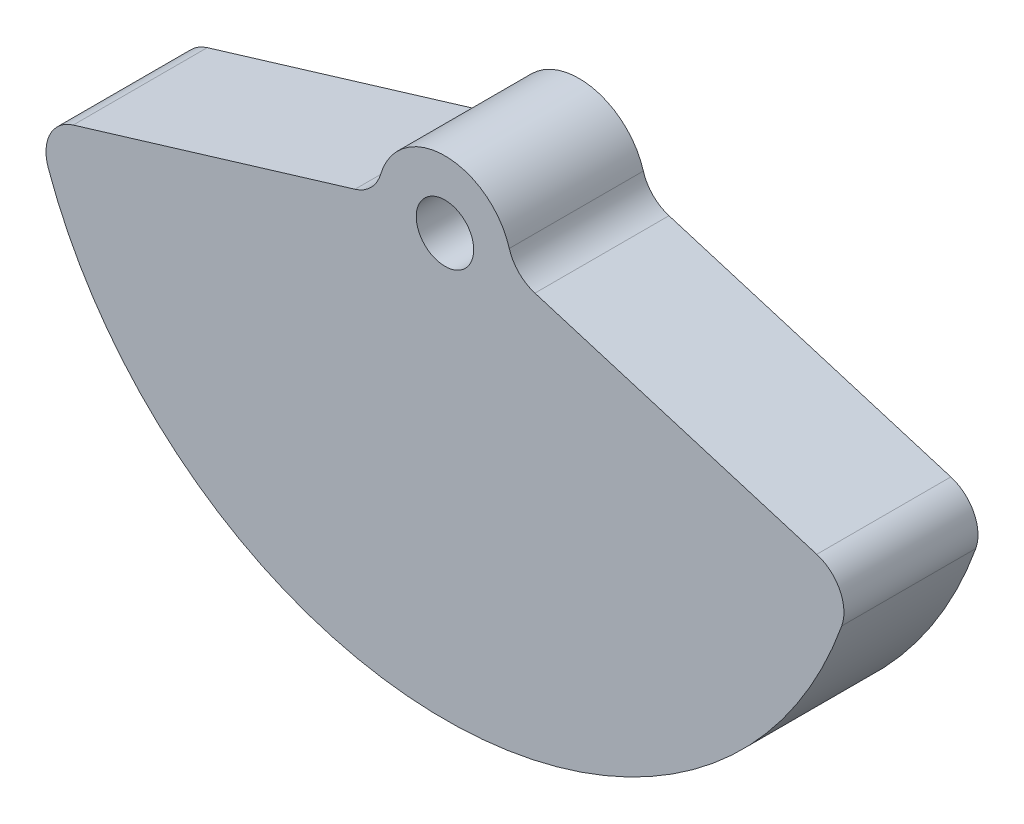
from build123d import *

# Parameters (mm, degrees)
SKETCH2_R           = 19.05
BOSS_EXTRUDE1_DEPTH = 44.45
SCALE1_SCALE        = 0.083333333


with BuildPart() as part:
    # Sketch2 → Boss-Extrude1 (new body, symmetric)
    with BuildSketch(Plane.XY):
        with BuildLine():
            Line((-246.541287735, -61.175642711), (-59.652807836, -4.602086269))
            ThreePointArc((-59.652807836, -4.602086269), (-48.980567788, 1.8190908), (-42.643954444, 12.541756231))
            ThreePointArc((-42.643954444, 12.541756231), (0, 44.45), (42.643954444, 12.541756231))
            ThreePointArc((42.643954444, 12.541756231), (48.980567788, 1.8190908), (59.652807836, -4.602086269))
            Line((59.652807836, -4.602086269), (246.541287735, -61.175642711))
            ThreePointArc((246.541287735, -61.175642711), (261.864746274, -74.055516083), (263.100383875, -94.034823363))
            ThreePointArc((263.100383875, -94.034823363), (0, -279.4), (-263.100383875, -94.034823363))
            ThreePointArc((-263.100383875, -94.034823363), (-261.864746274, -74.055516083), (-246.541287735, -61.175642711))
        make_face()
        Circle(SKETCH2_R, mode=Mode.SUBTRACT)
    extrude(amount=BOSS_EXTRUDE1_DEPTH, both=True)


with BuildPart() as part_1:
    # Scale1: scaled about (0, 0, 0)
    add(part.part.scale(SCALE1_SCALE))


solid = part_1.part
